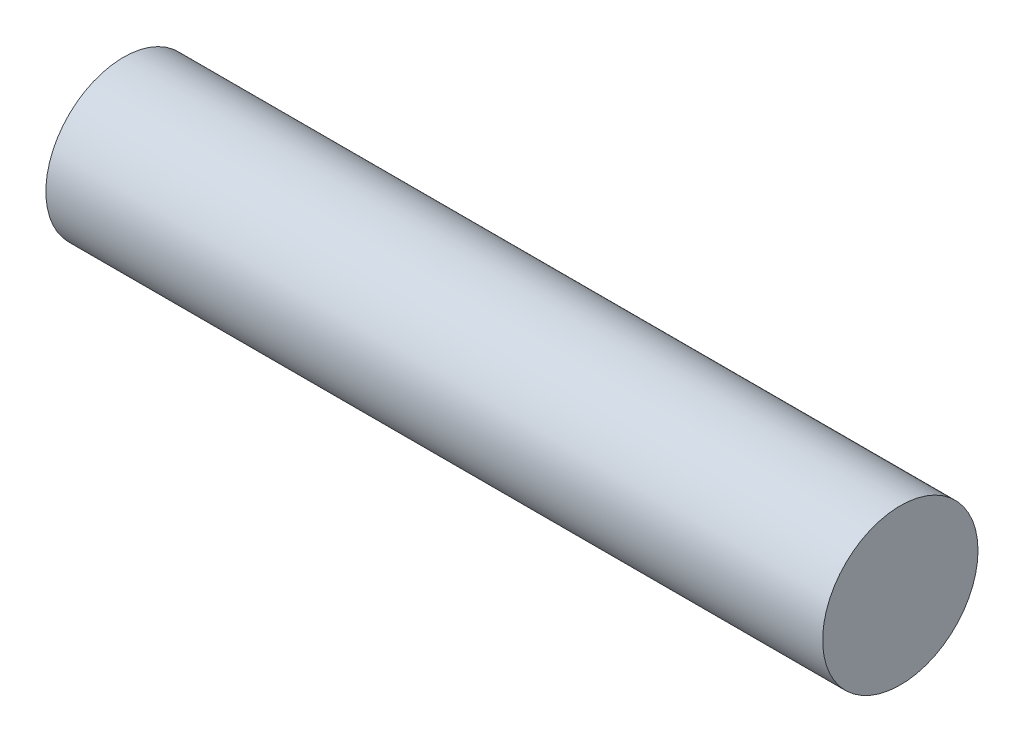
from build123d import *

# Parameters (mm, degrees)
SKETCH1_R           = 1.5875
BOSS_EXTRUDE1_DEPTH = 7.9375


with BuildPart() as part:
    # Sketch1 → Boss-Extrude1 (new body, symmetric)
    with BuildSketch(Plane(origin=(0, 0, 0), x_dir=(0, 0, -1), z_dir=(1, 0, 0))):
        Circle(SKETCH1_R)
    extrude(amount=BOSS_EXTRUDE1_DEPTH, both=True)


solid = part.part
